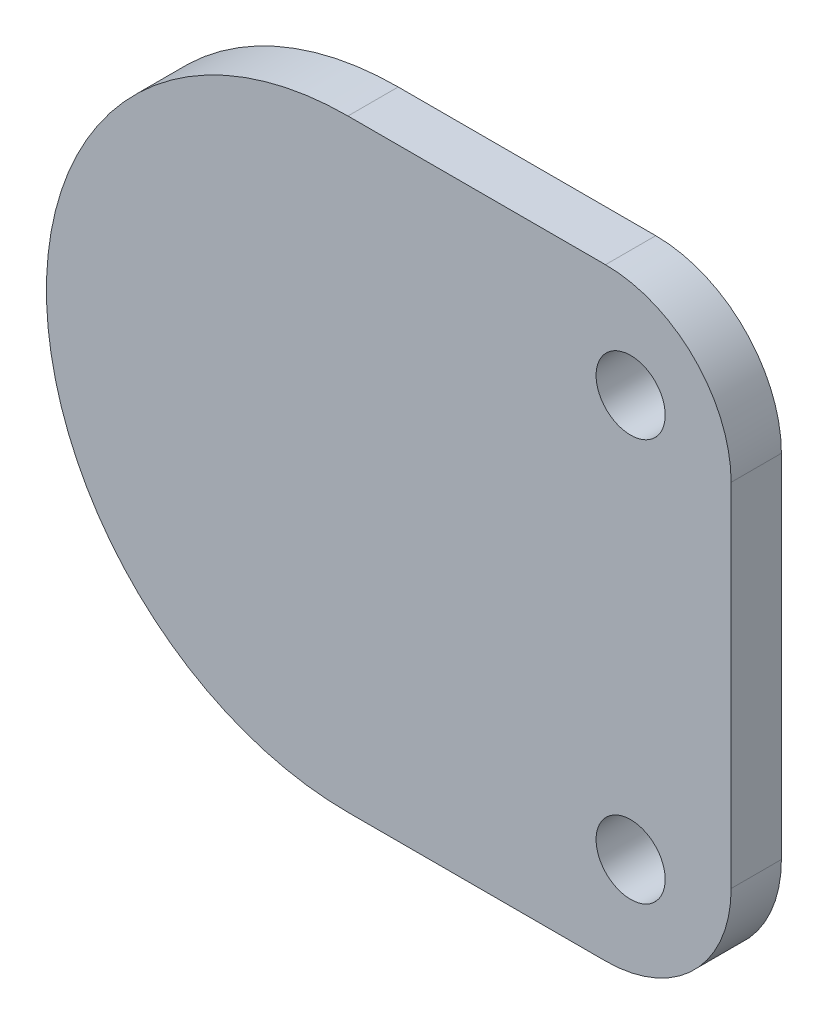
from build123d import *

# Parameters (mm, degrees)
SKETCH1_R           = 2.75
BOSS_EXTRUDE1_DEPTH = 4
SKETCH2_R           = 16
SKETCH2_R_2         = 14
BOSS_EXTRUDE2_DEPTH = 6


with BuildPart() as part:
    # Sketch1 → Boss-Extrude1 (new body)
    with BuildSketch(Plane.XY):
        with BuildLine():
            Line((0, -24), (20.5, -24))
            ThreePointArc((20.5, -24), (27.571067812, -21.071067812), (30.5, -14))
            Line((30.5, -14), (30.5, 14))
            ThreePointArc((30.5, 14), (27.571067812, 21.071067812), (20.5, 24))
            Line((20.5, 24), (0, 24))
            ThreePointArc((0, 24), (-24, 0), (0, -24))
        make_face()
        with Locations((22.5, -16)):
            Circle(SKETCH1_R, mode=Mode.SUBTRACT)
        with Locations((22.5, 16)):
            Circle(SKETCH1_R, mode=Mode.SUBTRACT)
    extrude(amount=BOSS_EXTRUDE1_DEPTH)

    # Sketch2 → Boss-Extrude2 (add)
    with BuildSketch(Plane(origin=(0, 0, 0), x_dir=(-1, 0, 0), z_dir=(0, 0, -1))):
        Circle(SKETCH2_R)
        Circle(SKETCH2_R_2, mode=Mode.SUBTRACT)
    extrude(amount=BOSS_EXTRUDE2_DEPTH)


solid = part.part
